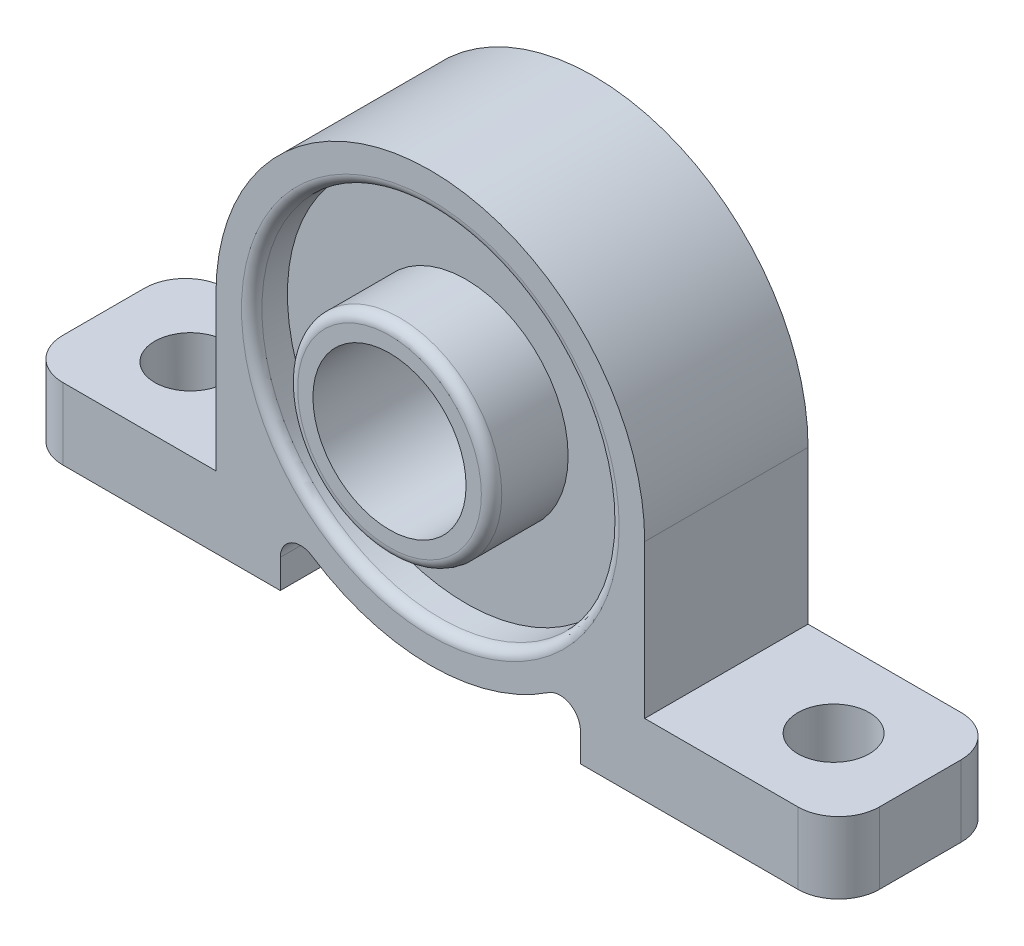
from build123d import *

# Parameters (mm, degrees)
SKETCH_1_R               = 7.5
EXTRUDE_1_DEPTH          = 16
SKETCH_2_R               = 10
SKETCH_2_R_2             = 7.5
EXTRUDE_2_DEPTH          = 4
SKETCH_3_R               = 17.5
SKETCH_3_R_2             = 10
CUT_EXTRUDE_1_DEPTH      = 3.5
SKETCH_4_R               = 17
CUT_EXTRUDE_2_DEPTH      = 3.5
FILLET_1_R               = 4
FILLET_2_R               = 2
FILLET_3_R               = 1
SKETCH_5_R               = 3.5
CUT_EXTRUDE_3_DEPTH      = 37
CUT_EXTRUDE_3_DEPTH_BACK = 8


with BuildPart() as part:
    # 草图1 → 凸台-拉伸1 (new body)
    with BuildSketch(Plane.XY):
        with BuildLine():
            Line((-40, 0), (-21, 0))
            Line((-21, 0), (-21, 15))
            ThreePointArc((-21, 15), (0, 36), (21, 15))
            Line((21, 15), (21, 0))
            Line((21, 0), (40, 0))
            Line((40, 0), (40, -7))
            Line((40, -7), (14.696938457, -7))
            Line((14.696938457, -7), (14.696938457, 0))
            ThreePointArc((14.696938457, 0), (0, -6), (-14.696938457, 0))
            Line((-14.696938457, 0), (-14.696938457, -7))
            Line((-14.696938457, -7), (-40, -7))
            Line((-40, -7), (-40, 0))
        make_face()
        with Locations((0, 15)):
            Circle(SKETCH_1_R, mode=Mode.SUBTRACT)
    extrude(amount=EXTRUDE_1_DEPTH)

    # 草图2 → 凸台-拉伸2 (add)
    with BuildSketch(Plane.XY.offset(16)):
        with Locations((0, 15)):
            Circle(SKETCH_2_R)
        with Locations((0, 15)):
            Circle(SKETCH_2_R_2, mode=Mode.SUBTRACT)
    extrude(amount=EXTRUDE_2_DEPTH)

    # 草图3 → 切除-拉伸1 (cut)
    with BuildSketch(Plane.XY.offset(16)):
        with Locations((0, 15)):
            Circle(SKETCH_3_R)
        with Locations((0, 15)):
            Circle(SKETCH_3_R_2, mode=Mode.SUBTRACT)
    extrude(amount=-CUT_EXTRUDE_1_DEPTH, mode=Mode.SUBTRACT)

    # 草图4 → 切除-拉伸2 (cut)
    with BuildSketch(Plane(origin=(0, 0, 0), x_dir=(-1, 0, 0), z_dir=(0, 0, -1))):
        with Locations((0, 15)):
            Circle(SKETCH_4_R)
    extrude(amount=-CUT_EXTRUDE_2_DEPTH, mode=Mode.SUBTRACT)

    # 圆角1
    fillet_1_edges = [part.edges().sort_by_distance(p)[0] for p in [
        (40, -3.5, 0),
        (-40, -3.5, 0),
        (40, -3.5, 16),
        (-40, -3.5, 16),
    ]]
    fillet(fillet_1_edges, radius=FILLET_1_R)

    # 圆角2
    fillet_2_edges = [part.edges().sort_by_distance(p)[0] for p in [
        (14.696938457, 0, 8),
        (-14.696938457, 0, 8),
    ]]
    fillet(fillet_2_edges, radius=FILLET_2_R)

    # 圆角3
    fillet_3_edges = [part.edges().sort_by_distance(p)[0] for p in [
        (-10, 15, 20),
        (-17.5, 15, 16),
        (-7.5, 15, 3.5),
        (17, 15, 0),
    ]]
    fillet(fillet_3_edges, radius=FILLET_3_R)

    # 草图5 → 切除-拉伸3 (cut, two sides)
    with BuildSketch(Plane(origin=(0, 0, 0), x_dir=(1, 0, 0), z_dir=(0, 1, 0))) as cut_extrude_3_sk:
        with Locations((-31.5, -8)):
            Circle(SKETCH_5_R)
        with Locations((31.5, -8)):
            Circle(SKETCH_5_R)
    extrude(amount=CUT_EXTRUDE_3_DEPTH, mode=Mode.SUBTRACT)
    extrude(cut_extrude_3_sk.sketch, amount=-CUT_EXTRUDE_3_DEPTH_BACK, mode=Mode.SUBTRACT)


solid = part.part
